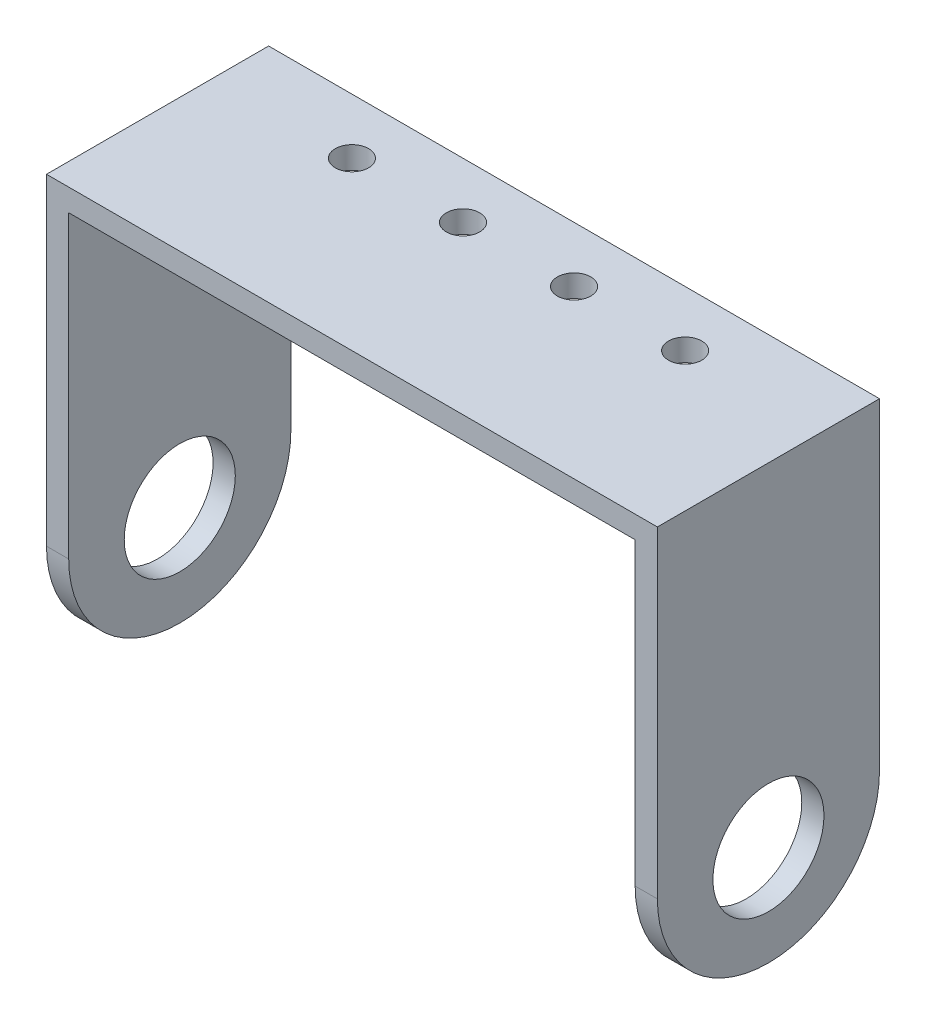
from build123d import *

# Parameters (mm, degrees)
SKETCH1_W           = 55
SKETCH1_H           = 20
BOSS_EXTRUDE1_DEPTH = 2
SKETCH2_W           = 2
SKETCH2_H           = 20
BOSS_EXTRUDE2_DEPTH = 37
SKETCH3_R           = 5
CUT_EXTRUDE1_DEPTH  = 56
CUT_EXTRUDE2_DEPTH  = 56
SKETCH5_R           = 1.5
CUT_EXTRUDE3_DEPTH  = 40


with BuildPart() as part:
    # Sketch1 → Boss-Extrude1 (new body)
    with BuildSketch(Plane(origin=(0, 0, 0), x_dir=(1, 0, 0), z_dir=(0, 1, 0))):
        Rectangle(SKETCH1_W, SKETCH1_H)
    extrude(amount=-BOSS_EXTRUDE1_DEPTH)

    # Sketch2 → Boss-Extrude2 (add)
    with BuildSketch(Plane.XZ.offset(2)):
        with Locations((-26.5, 0)):
            Rectangle(SKETCH2_W, SKETCH2_H)
        with Locations((26.5, 0)):
            Rectangle(SKETCH2_W, SKETCH2_H)
    extrude(amount=BOSS_EXTRUDE2_DEPTH)

    # Sketch3 → Cut-Extrude1 (cut, through all)
    with BuildSketch(Plane(origin=(27.5, 0, 0), x_dir=(0, 0, -1), z_dir=(1, 0, 0))):
        with Locations((0, -30)):
            Circle(SKETCH3_R)
    extrude(amount=-CUT_EXTRUDE1_DEPTH, mode=Mode.SUBTRACT)

    # Sketch4 → Cut-Extrude2 (cut, through all)
    with BuildSketch(Plane.ZY.offset(27.5)):
        with BuildLine():
            ThreePointArc((0, -39), (-7.071067812, -36.071067812), (-10, -29))
            Line((-10, -29), (-10, -39))
            Line((-10, -39), (0, -39))
        make_face()
        with BuildLine():
            Line((10, -39), (10, -29))
            ThreePointArc((10, -29), (7.071067812, -36.071067812), (0, -39))
            Line((0, -39), (10, -39))
        make_face()
    extrude(amount=-CUT_EXTRUDE2_DEPTH, mode=Mode.SUBTRACT)

    # Sketch5 → Cut-Extrude3 (cut, through all)
    with BuildSketch(Plane(origin=(0, 0, 0), x_dir=(1, 0, 0), z_dir=(0, 1, 0))):
        with Locations((5, 5)):
            Circle(SKETCH5_R)
        with Locations((15, 5)):
            Circle(SKETCH5_R)
        with Locations((-15, 5)):
            Circle(SKETCH5_R)
        with Locations((-5, 5)):
            Circle(SKETCH5_R)
    extrude(amount=-CUT_EXTRUDE3_DEPTH, mode=Mode.SUBTRACT)


solid = part.part
